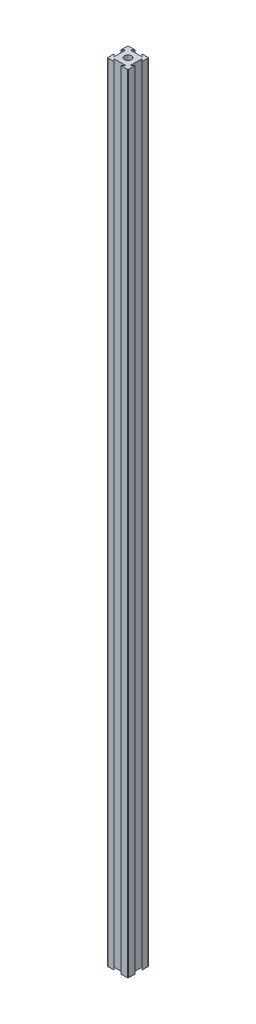
from build123d import *

# Parameters (mm, degrees)
SKETCH1_R           = 3.333333333
BOSS_EXTRUDE1_DEPTH = 762
FILLET4_R           = 0.508


with BuildPart() as part:
    # Sketch1 → Boss-Extrude1 (new body)
    with BuildSketch(Plane(origin=(0, 0, 0), x_dir=(1, 0, 0), z_dir=(0, 1, 0))):
        Polygon((4.285, 17.618333333), (6.666666667, 20), (0, 20), (0, 13.333333333), (2.381666667, 15.715), (2.381666667, 4.285), (0, 6.666666667), (0, 0), (6.666666667, 0), (4.285, 2.381666667), (15.715, 2.381666667), (13.333333333, 0), (20, 0), (20, 6.666666667), (17.618333333, 4.285), (17.618333333, 15.715), (20, 13.333333333), (20, 20), (13.333333333, 20), (15.715, 17.618333333), align=None)
        with Locations((10, 10)):
            Circle(SKETCH1_R, mode=Mode.SUBTRACT)
    extrude(amount=BOSS_EXTRUDE1_DEPTH)

    # Fillet4
    fillet4_edges = [part.edges().sort_by_distance(p)[0] for p in [
        (20, 381, 0),
        (0, 381, 0),
        (0, 381, -20),
        (20, 381, -20),
    ]]
    fillet(fillet4_edges, radius=FILLET4_R)


solid = part.part
